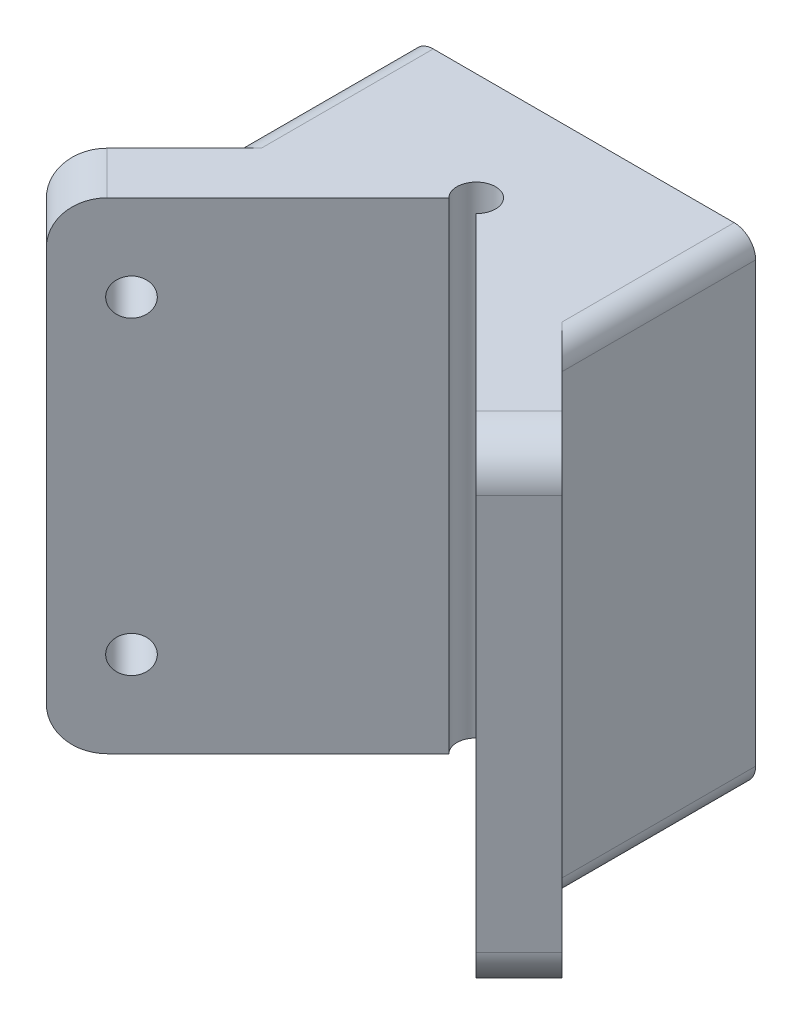
from build123d import *

# Parameters (mm, degrees)
ESQUISSE1_W                  = 80
ESQUISSE1_H                  = 112
BOSS_EXTRU_1_DEPTH           = 100
ESQUISSE4_R                  = 2.5
ENL_V_MAT_EXTRU_2_DEPTH      = 100
ENL_V_MAT_EXTRU_2_DEPTH_BACK = 1
BOSS_EXTRU_2_DEPTH           = 112
BOSS_EXTRU_4_DEPTH           = 112
ENL_V_MAT_EXTRU_6_DEPTH      = 112
ESQUISSE16_R                 = 4.25
ENL_V_MAT_EXTRU_7_DEPTH      = 112
ESQUISSE15_R                 = 4.25
ENL_V_MAT_EXTRU_10_DEPTH     = 112
CONG_1_R                     = 10
CONG_2_R                     = 5
ESQUISSE17_R                 = 4.5
ENL_V_MAT_EXTRU_12_DEPTH     = 112


with BuildPart() as part:
    # Esquisse1 → Boss.-Extru.1 (new body)
    with BuildSketch(Plane.XY):
        Rectangle(ESQUISSE1_W, ESQUISSE1_H)
    extrude(amount=BOSS_EXTRU_1_DEPTH)

    # Esquisse4 → Enlèv. mat.-Extru.2 (cut, two sides)
    with BuildSketch(Plane.XY) as enl_v_mat_extru_2_sk:
        with Locations((-32, 47.99765818)):
            Circle(ESQUISSE4_R)
        with Locations((32, 48)):
            Circle(ESQUISSE4_R)
        with Locations((-32, -48)):
            Circle(ESQUISSE4_R)
        with Locations((32, -48)):
            Circle(ESQUISSE4_R)
    extrude(amount=ENL_V_MAT_EXTRU_2_DEPTH, mode=Mode.SUBTRACT)
    extrude(enl_v_mat_extru_2_sk.sketch, amount=-ENL_V_MAT_EXTRU_2_DEPTH_BACK, mode=Mode.SUBTRACT)

    # Esquisse11 → Boss.-Extru.2 (add)
    with BuildSketch(Plane(origin=(0, 56, 0), x_dir=(1, 0, 0), z_dir=(0, 1, 0))):
        Polygon((-60, -65), (0, -5), (60, -65), align=None)
    extrude(amount=-BOSS_EXTRU_2_DEPTH)

    # Esquisse13 → Boss.-Extru.4 (add)
    with BuildSketch(Plane(origin=(0, 56, 0), x_dir=(1, 0, 0), z_dir=(0, 1, 0))):
        Polygon((-60, -65), (-40, -85), (-40, -65), align=None)
        Polygon((60, -65), (40, -85), (40, -65), align=None)
    extrude(amount=-BOSS_EXTRU_4_DEPTH)

    # Esquisse14 → Enlèv. mat.-Extru.6 (cut)
    with BuildSketch(Plane(origin=(0, 56, 0), x_dir=(1, 0, 0), z_dir=(0, 1, 0))):
        Polygon((-50, -75), (0, -25), (50, -75), (40, -85), (40, -100), (-40, -100), (-40, -85), align=None)
    extrude(amount=-ENL_V_MAT_EXTRU_6_DEPTH, mode=Mode.SUBTRACT)

    # Esquisse16 → Enlèv. mat.-Extru.7 (cut)
    with BuildSketch(Plane(origin=(2.5, 0, 2.5), x_dir=(-0.707106781, 0, 0.707106781), z_dir=(-0.707106781, 0, -0.707106781))):
        with Locations((74.388347648, 36)):
            Circle(ESQUISSE16_R)
        with Locations((74.388347648, -36)):
            Circle(ESQUISSE16_R)
    extrude(amount=-ENL_V_MAT_EXTRU_7_DEPTH, mode=Mode.SUBTRACT)

    # Esquisse15 → Enlèv. mat.-Extru.10 (cut)
    with BuildSketch(Plane(origin=(-2.5, 0, 2.5), x_dir=(-0.707106781, 0, -0.707106781), z_dir=(0.707106781, 0, -0.707106781))):
        with Locations((-74.388347648, 36)):
            Circle(ESQUISSE15_R)
        with Locations((-74.388347648, -36)):
            Circle(ESQUISSE15_R)
    extrude(amount=-ENL_V_MAT_EXTRU_10_DEPTH, mode=Mode.SUBTRACT)

    # Congé1
    cong_1_edges = [part.edges().sort_by_distance(p)[0] for p in [
        (-55, -56, 70),
        (-55, 56, 70),
        (55, 56, 70),
        (55, -56, 70),
    ]]
    fillet(cong_1_edges, radius=CONG_1_R)

    # Congé2
    cong_2_edges = [part.edges().sort_by_distance(p)[0] for p in [
        (40, -56, 22.5),
        (-40, -56, 22.5),
        (-40, 56, 22.5),
        (40, 56, 22.5),
    ]]
    fillet(cong_2_edges, radius=CONG_2_R)

    # Esquisse17 → Enlèv. mat.-Extru.12 (cut)
    with BuildSketch(Plane(origin=(0, 56, 0), x_dir=(1, 0, 0), z_dir=(0, 1, 0))):
        with Locations((0, -25)):
            Circle(ESQUISSE17_R)
    extrude(amount=-ENL_V_MAT_EXTRU_12_DEPTH, mode=Mode.SUBTRACT)


solid = part.part
